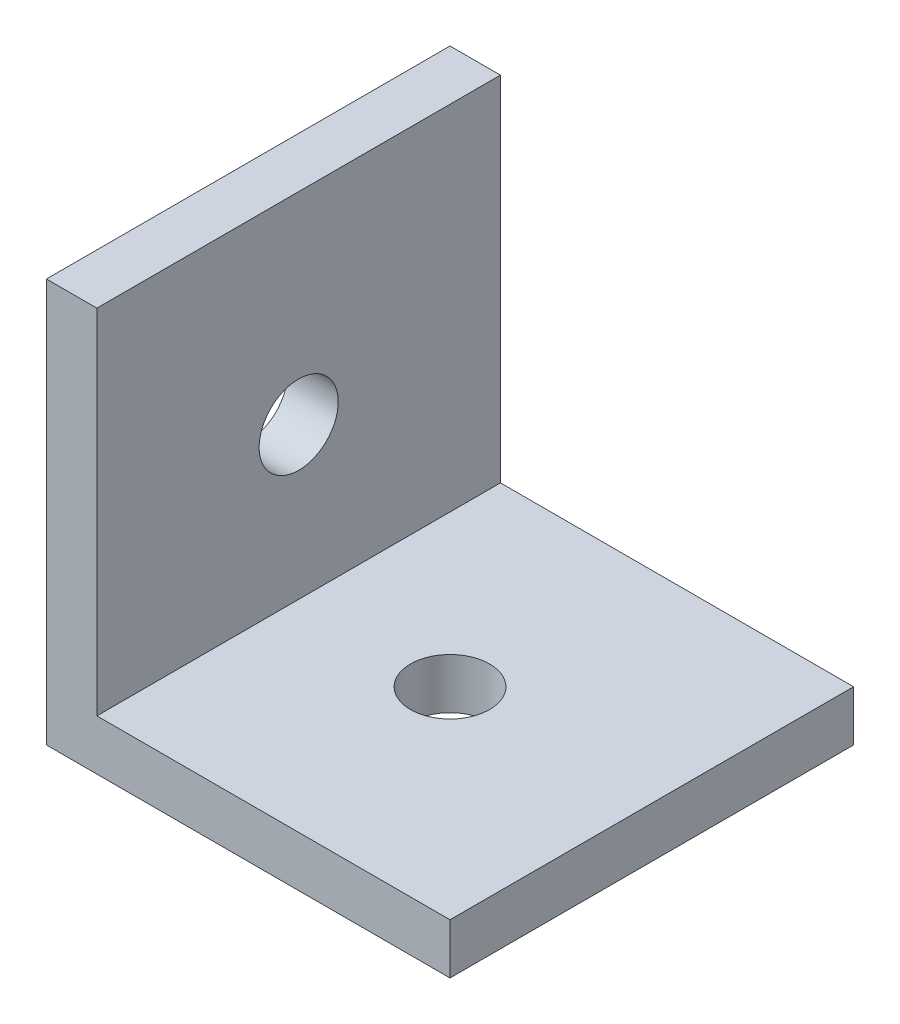
from build123d import *

# Parameters (mm, degrees)
EXTRUDE_THIN1_DEPTH = 25.4
SKETCH2_R           = 2.4892
CUT_EXTRUDE1_DEPTH  = 26.4


with BuildPart() as part:
    # Sketch1 → Extrude-Thin1 (new body)
    with BuildSketch(Plane.XY):
        Polygon((25.4, 0), (0, 0), (0, 25.4), (3.175, 25.4), (3.175, 3.175), (25.4, 3.175), align=None)
    extrude(amount=-EXTRUDE_THIN1_DEPTH)

    # Sketch2 → Cut-Extrude1 (cut, through all)
    with BuildSketch(Plane.XZ):
        with Locations((12.7, -12.7)):
            Circle(SKETCH2_R)
    cut_extrude1 = extrude(amount=-CUT_EXTRUDE1_DEPTH, mode=Mode.SUBTRACT)

    # Mirror1: Cut-Extrude1 across plane
    add(cut_extrude1.mirror(Plane(origin=(0, 0, 0), x_dir=(0, 0, 1), z_dir=(0.707106781, -0.707106781, 0))), mode=Mode.SUBTRACT)


solid = part.part
